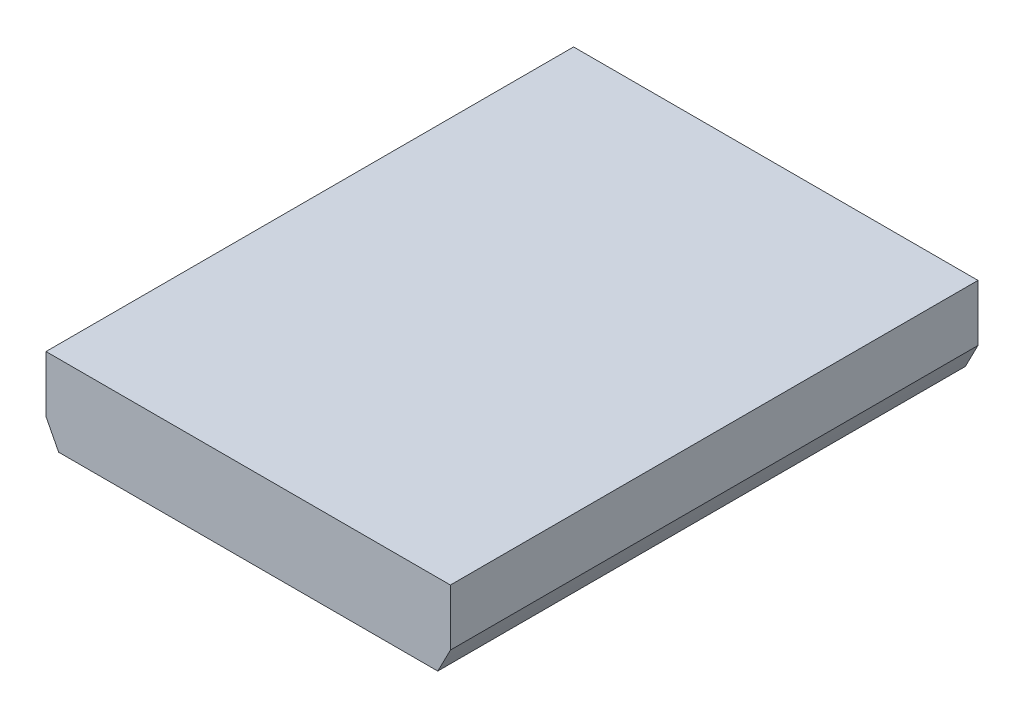
from build123d import *

# Parameters (mm, degrees)
BOSS_EXTRUDE2_DEPTH = 331.382
SKETCH3_W           = 66
SKETCH3_H           = 122
CUT_EXTRUDE2_DEPTH  = 128.0000001
SKETCH4_W           = 240
SKETCH4_H           = 111.6
CUT_EXTRUDE3_DEPTH  = 332.3820001
SKETCH5_W           = 254
SKETCH5_H           = 35.4
BOSS_EXTRUDE3_DEPTH = 331.382


with BuildPart() as part:
    # Sketch2 → Boss-Extrude2 (new body)
    with BuildSketch(Plane.XY):
        with BuildLine():
            Line((-127, 127), (127, 127))
            add(Edge.make_bspline(
                [(-127, 127), (0, -127), (127, 127)],
                knots=[0.056028396, 0.056028396, 0.056028396, 0.943971604, 0.943971604, 0.943971604], degree=2))
        make_face()
    extrude(amount=BOSS_EXTRUDE2_DEPTH)

    # Sketch3 → Cut-Extrude2 (cut, through all)
    with BuildSketch(Plane(origin=(0, 127, 0), x_dir=(1, 0, 0), z_dir=(0, 1, 0))):
        with Locations((0, -82.8455)):
            Rectangle(SKETCH3_W, SKETCH3_H)
        with Locations((0, -248.5365)):
            Rectangle(SKETCH3_W, SKETCH3_H)
    extrude(amount=-CUT_EXTRUDE2_DEPTH, mode=Mode.SUBTRACT)

    # Sketch4 → Cut-Extrude3 (cut, through all)
    with BuildSketch(Plane(origin=(0, 0, 0), x_dir=(-1, 0, 0), z_dir=(0, 0, -1))):
        with Locations((0, 55.8)):
            Rectangle(SKETCH4_W, SKETCH4_H)
    extrude(amount=-CUT_EXTRUDE3_DEPTH, mode=Mode.SUBTRACT)

    # Sketch5 → Boss-Extrude3 (add)
    with BuildSketch(Plane.XY.offset(331.382)):
        with Locations((0, 144.7)):
            Rectangle(SKETCH5_W, SKETCH5_H)
    extrude(amount=-BOSS_EXTRUDE3_DEPTH)


solid = part.part
